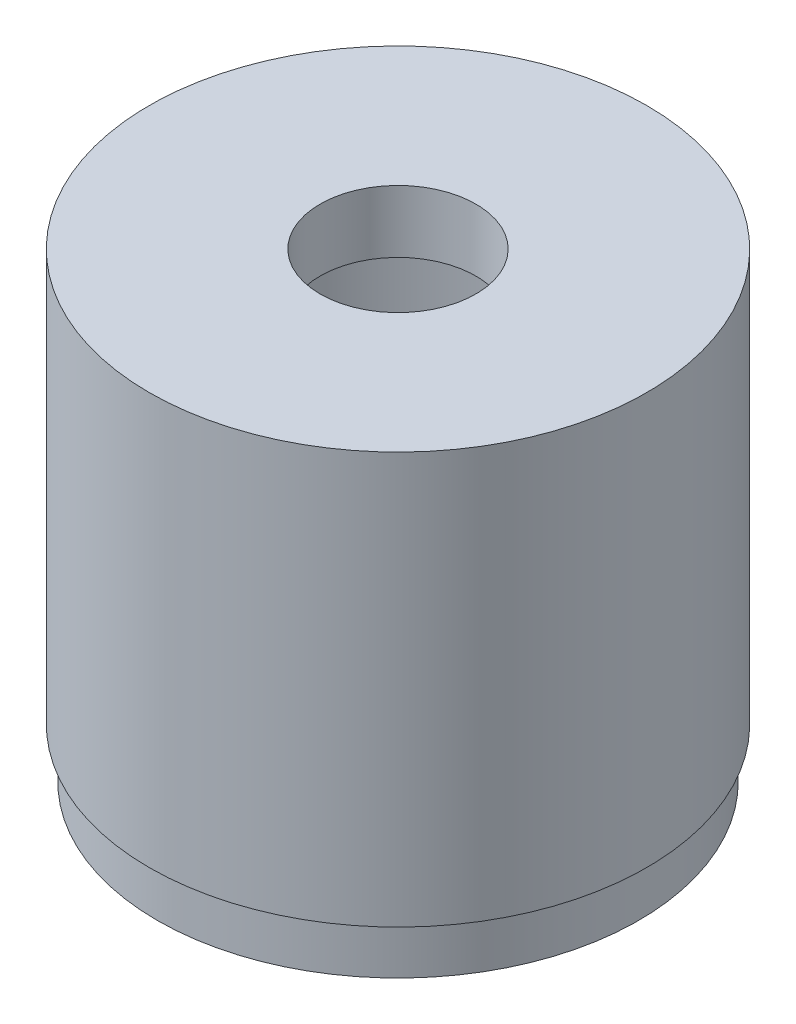
from build123d import *

# Parameters (mm, degrees)
SKETCH1_R           = 24.511
SKETCH1_R_2         = 21.971
BOSS_EXTRUDE1_DEPTH = 40.64
SKETCH2_R           = 24.511
BOSS_EXTRUDE2_DEPTH = 6.35
CUT_EXTRUDE1_REACH  = 48.99
SKETCH3_R           = 7.9375
SKETCH4_R           = 25.3365
SKETCH4_R_2         = 24.511
BOSS_EXTRUDE3_DEPTH = 41.91


with BuildPart() as part:
    # Sketch1 → Boss-Extrude1 (new body)
    with BuildSketch(Plane(origin=(0, 0, 0), x_dir=(1, 0, 0), z_dir=(0, 1, 0))):
        Circle(SKETCH1_R)
        Circle(SKETCH1_R_2, mode=Mode.SUBTRACT)
    extrude(amount=BOSS_EXTRUDE1_DEPTH)

    # Sketch2 → Boss-Extrude2 (add)
    with BuildSketch(Plane(origin=(0, 40.64, 0), x_dir=(1, 0, 0), z_dir=(0, 1, 0))):
        Circle(SKETCH2_R)
    extrude(amount=BOSS_EXTRUDE2_DEPTH)

    # Sketch3 → Cut-Extrude1 (cut, up to next)
    with BuildSketch(Plane(origin=(0, 46.99, 0), x_dir=(1, 0, 0), z_dir=(0, 1, 0)), mode=Mode.PRIVATE) as cut_extrude1_sk1:
        Circle(SKETCH3_R)
    cut_extrude1_tool1 = extrude(cut_extrude1_sk1.sketch, amount=-CUT_EXTRUDE1_REACH, mode=Mode.PRIVATE) & part.part
    add(cut_extrude1_tool1.solids().sort_by_distance((0, 46.99, 0))[0], mode=Mode.SUBTRACT)

    # Sketch4 → Boss-Extrude3 (add)
    with BuildSketch(Plane(origin=(0, 46.99, 0), x_dir=(1, 0, 0), z_dir=(0, 1, 0))):
        Circle(SKETCH4_R)
        Circle(SKETCH4_R_2, mode=Mode.SUBTRACT)
    extrude(amount=-BOSS_EXTRUDE3_DEPTH)


solid = part.part
